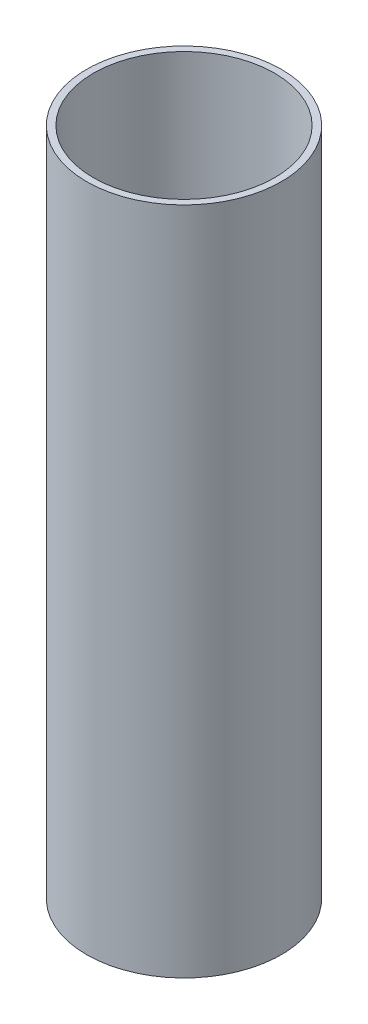
from build123d import *

# Parameters (mm, degrees)
SKETCH1_R           = 29.083
SKETCH1_R_2         = 27.06751
BOSS_EXTRUDE1_DEPTH = 200


with BuildPart() as part:
    # Sketch1 → Boss-Extrude1 (new body)
    with BuildSketch(Plane(origin=(0, 0, 0), x_dir=(1, 0, 0), z_dir=(0, 1, 0))):
        Circle(SKETCH1_R)
        Circle(SKETCH1_R_2, mode=Mode.SUBTRACT)
    extrude(amount=BOSS_EXTRUDE1_DEPTH)


solid = part.part
